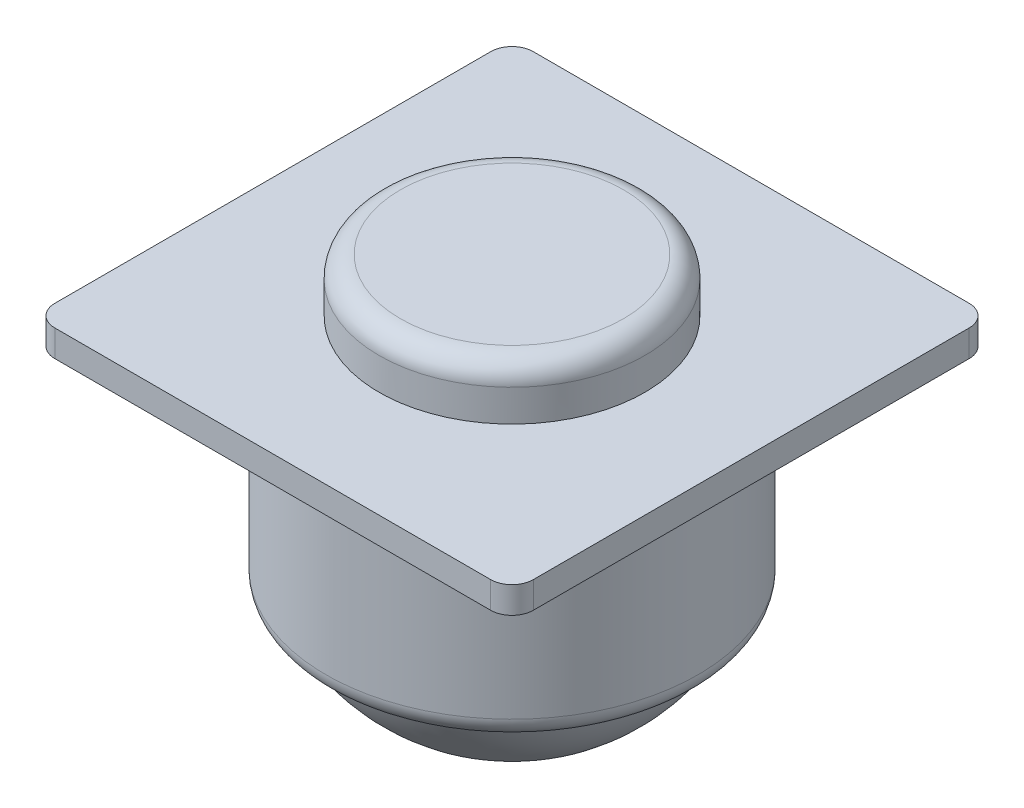
from build123d import *

# Parameters (mm, degrees)
SKETCH1_W           = 28.575
SKETCH1_H           = 28.575
BOSS_EXTRUDE1_DEPTH = 1.5875
SKETCH2_R           = 7.9375
BOSS_EXTRUDE2_DEPTH = 3.175
SKETCH3_R           = 11.1125
BOSS_EXTRUDE3_DEPTH = 12.7
FILLET1_R           = 1.27
DOME1_FACE_RADIUS   = 9.8425
DOME1_HEIGHT        = 6.35
FILLET2_R           = 1.27


with BuildPart() as part:
    # Sketch1 → Boss-Extrude1 (new body)
    with BuildSketch(Plane(origin=(0, 0, 0), x_dir=(1, 0, 0), z_dir=(0, 1, 0))):
        Rectangle(SKETCH1_W, SKETCH1_H)
    extrude(amount=BOSS_EXTRUDE1_DEPTH)

    # Sketch2 → Boss-Extrude2 (add)
    with BuildSketch(Plane(origin=(0, 1.5875, 0), x_dir=(1, 0, 0), z_dir=(0, 1, 0))):
        Circle(SKETCH2_R)
    extrude(amount=BOSS_EXTRUDE2_DEPTH)

    # Sketch3 → Boss-Extrude3 (add)
    with BuildSketch(Plane.XZ):
        Circle(SKETCH3_R)
    extrude(amount=BOSS_EXTRUDE3_DEPTH)

    # Fillet1
    fillet1_edges = [part.edges().sort_by_distance(p)[0] for p in [
        (-7.9375, 4.7625, 0),
        (-11.1125, -12.7, 0),
    ]]
    fillet(fillet1_edges, radius=FILLET1_R)

    # Dome1: a dome of height H over a round flat face of radius A is a cap of a sphere of radius (A * A + H * H) / (2 * H)
    dome1_r = (DOME1_FACE_RADIUS * DOME1_FACE_RADIUS + DOME1_HEIGHT * DOME1_HEIGHT) / (2 * DOME1_HEIGHT)
    dome1_base = Plane((0, -12.7, 0), z_dir=(0, -1, 0))
    with Locations(dome1_base.offset(DOME1_HEIGHT - dome1_r)):
        dome1_ball = Sphere(dome1_r, mode=Mode.PRIVATE)
    add(split(dome1_ball, bisect_by=dome1_base, keep=Keep.TOP, mode=Mode.PRIVATE))

    # Fillet2
    fillet2_edges = [part.edges().sort_by_distance(p)[0] for p in [
        (14.2875, 0.79375, 14.2875),
        (-14.2875, 0.79375, 14.2875),
        (-14.2875, 0.79375, -14.2875),
        (14.2875, 0.79375, -14.2875),
    ]]
    fillet(fillet2_edges, radius=FILLET2_R)


solid = part.part
